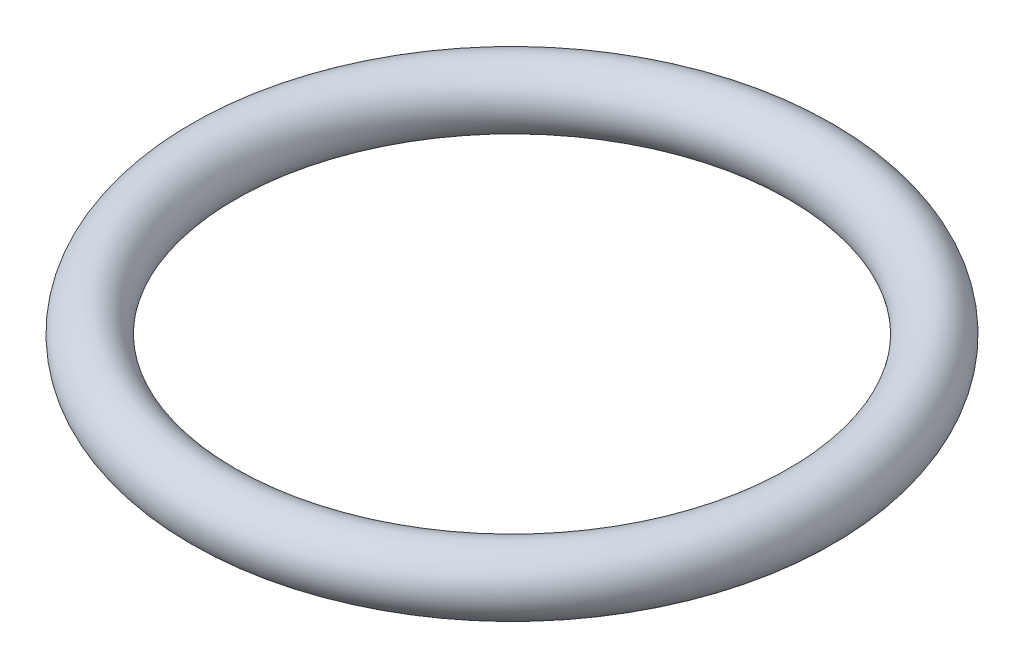
from build123d import *

# Parameters (mm, degrees)
SKETCH1_R = 0.889


with BuildPart() as part:
    # Sketch1 → Revolve1 (revolve)
    with BuildSketch(Plane.XY):
        with Locations((-8.585, 0)):
            Circle(SKETCH1_R)
    revolve(axis=Axis((0, 0, 0), (0, 1, 0)))


solid = part.part
